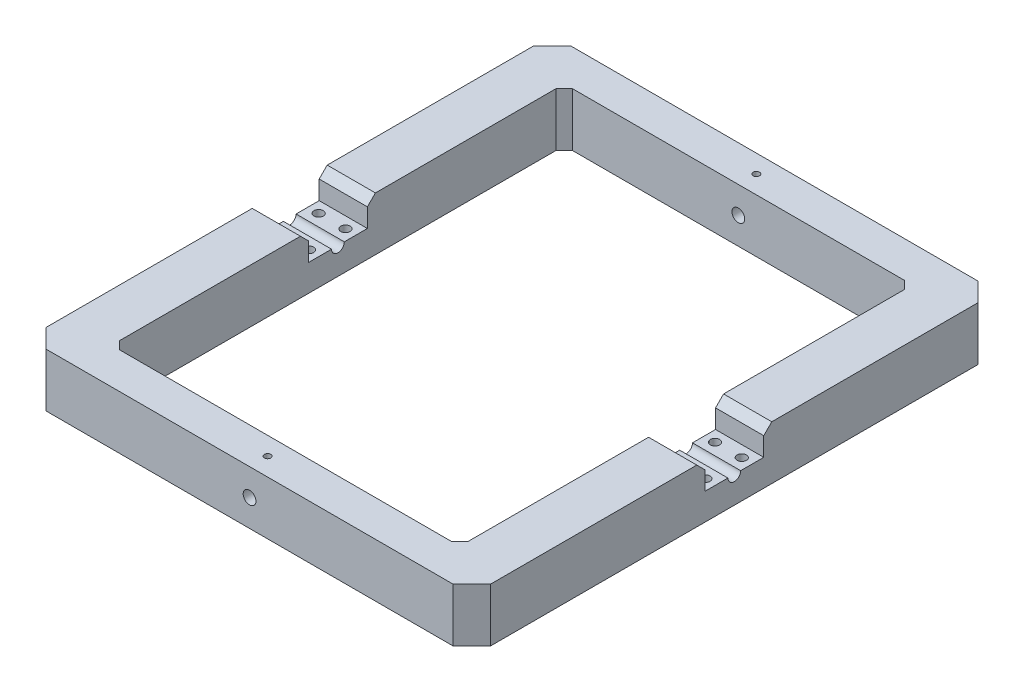
from build123d import *

# Parameters (mm, degrees)
SKETCH1_W               = 166
SKETCH1_H               = 196
SKETCH1_W_2             = 130
SKETCH1_H_2             = 160
BOSS_EXTRUDE1_DEPTH     = 10
CUT_EXTRUDE1_REACH      = 168
SKETCH2_R               = 2.38125
CUT_EXTRUDE2_DEPTH      = 167
SKETCH5_R               = 2.38125
CUT_EXTRUDE4_DEPTH      = 1
CUT_EXTRUDE4_DEPTH_BACK = 197
CUT_EXTRUDE5_REACH      = 12
SKETCH6_R               = 1.75
CUT_EXTRUDE7_REACH      = 22
SKETCH8_W               = 130
SKETCH8_H               = 4.5
CHAMFER9_SIZE           = 7
CHAMFER10_SIZE          = 3
CUT_EXTRUDE8_REACH      = 22
SKETCH9_R               = 1.190625
CHAMFER11_SIZE          = 3


with BuildPart() as part:
    # Sketch1 → Boss-Extrude1 (new body, symmetric)
    with BuildSketch(Plane(origin=(0, 0, 0), x_dir=(1, 0, 0), z_dir=(0, 1, 0))):
        Rectangle(SKETCH1_W, SKETCH1_H)
        Rectangle(SKETCH1_W_2, SKETCH1_H_2, mode=Mode.SUBTRACT)
    extrude(amount=BOSS_EXTRUDE1_DEPTH, both=True)

    # Sketch2 → Cut-Extrude1 (cut, up to next)
    with BuildSketch(Plane(origin=(83, 0, 0), x_dir=(0, 0, -1), z_dir=(1, 0, 0)), mode=Mode.PRIVATE) as cut_extrude1_sk1:
        Circle(SKETCH2_R)
    cut_extrude1_tool1 = extrude(cut_extrude1_sk1.sketch, amount=-CUT_EXTRUDE1_REACH, mode=Mode.PRIVATE) & part.part
    add(cut_extrude1_tool1.solids().sort_by_distance((83, 0, 0))[0], mode=Mode.SUBTRACT)

    # Sketch3 → Cut-Extrude2 (cut, through all)
    with BuildSketch(Plane.ZY.offset(83)):
        with BuildLine():
            ThreePointArc((-2.38125, 0), (0, 2.38125), (2.38125, 0))
            Line((2.38125, 0), (11, 0))
            Line((11, 0), (11, 10))
            Line((11, 10), (-11, 10))
            Line((-11, 10), (-11, 0))
            Line((-11, 0), (-2.38125, 0))
        make_face()
        with BuildLine():
            ThreePointArc((-2.38125, 0), (0, -2.38125), (2.38125, 0))
            Line((2.38125, 0), (-2.38125, 0))
        make_face()
        with BuildLine():
            Line((-2.38125, 0), (2.38125, 0))
            ThreePointArc((2.38125, 0), (0, 2.38125), (-2.38125, 0))
        make_face()
    extrude(amount=-CUT_EXTRUDE2_DEPTH, mode=Mode.SUBTRACT)

    # Sketch5 → Cut-Extrude4 (cut, two sides)
    with BuildSketch(Plane.XY.offset(98)) as cut_extrude4_sk:
        Circle(SKETCH5_R)
    extrude(amount=CUT_EXTRUDE4_DEPTH, mode=Mode.SUBTRACT)
    extrude(cut_extrude4_sk.sketch, amount=-CUT_EXTRUDE4_DEPTH_BACK, mode=Mode.SUBTRACT)

    # Sketch6 → Cut-Extrude5 (cut, up to next)
    with BuildSketch(Plane(origin=(0, 0, 0), x_dir=(1, 0, 0), z_dir=(0, 1, 0)), mode=Mode.PRIVATE) as cut_extrude5_sk1:
        with Locations((-69, 6.8)):
            Circle(SKETCH6_R)
    cut_extrude5_tool1 = extrude(cut_extrude5_sk1.sketch, amount=-CUT_EXTRUDE5_REACH, mode=Mode.PRIVATE) & part.part
    add(cut_extrude5_tool1.solids().sort_by_distance((-69, 0, -6.8))[0], mode=Mode.SUBTRACT)
    # Sketch6 → Cut-Extrude5 (cut, up to next)
    with BuildSketch(Plane(origin=(0, 0, 0), x_dir=(1, 0, 0), z_dir=(0, 1, 0)), mode=Mode.PRIVATE) as cut_extrude5_sk2:
        with Locations((-69, -6.8)):
            Circle(SKETCH6_R)
    cut_extrude5_tool2 = extrude(cut_extrude5_sk2.sketch, amount=-CUT_EXTRUDE5_REACH, mode=Mode.PRIVATE) & part.part
    add(cut_extrude5_tool2.solids().sort_by_distance((-69, 0, 6.8))[0], mode=Mode.SUBTRACT)
    # Sketch6 → Cut-Extrude5 (cut, up to next)
    with BuildSketch(Plane(origin=(0, 0, 0), x_dir=(1, 0, 0), z_dir=(0, 1, 0)), mode=Mode.PRIVATE) as cut_extrude5_sk3:
        with Locations((-79, -6.8)):
            Circle(SKETCH6_R)
    cut_extrude5_tool3 = extrude(cut_extrude5_sk3.sketch, amount=-CUT_EXTRUDE5_REACH, mode=Mode.PRIVATE) & part.part
    add(cut_extrude5_tool3.solids().sort_by_distance((-79, 0, 6.8))[0], mode=Mode.SUBTRACT)
    # Sketch6 → Cut-Extrude5 (cut, up to next)
    with BuildSketch(Plane(origin=(0, 0, 0), x_dir=(1, 0, 0), z_dir=(0, 1, 0)), mode=Mode.PRIVATE) as cut_extrude5_sk4:
        with Locations((-79, 6.8)):
            Circle(SKETCH6_R)
    cut_extrude5_tool4 = extrude(cut_extrude5_sk4.sketch, amount=-CUT_EXTRUDE5_REACH, mode=Mode.PRIVATE) & part.part
    add(cut_extrude5_tool4.solids().sort_by_distance((-79, 0, -6.8))[0], mode=Mode.SUBTRACT)
    # Sketch6 → Cut-Extrude5 (cut, up to next)
    with BuildSketch(Plane(origin=(0, 0, 0), x_dir=(1, 0, 0), z_dir=(0, 1, 0)), mode=Mode.PRIVATE) as cut_extrude5_sk5:
        with Locations((79, 6.8)):
            Circle(SKETCH6_R)
    cut_extrude5_tool5 = extrude(cut_extrude5_sk5.sketch, amount=-CUT_EXTRUDE5_REACH, mode=Mode.PRIVATE) & part.part
    add(cut_extrude5_tool5.solids().sort_by_distance((79, 0, -6.8))[0], mode=Mode.SUBTRACT)
    # Sketch6 → Cut-Extrude5 (cut, up to next)
    with BuildSketch(Plane(origin=(0, 0, 0), x_dir=(1, 0, 0), z_dir=(0, 1, 0)), mode=Mode.PRIVATE) as cut_extrude5_sk6:
        with Locations((79, -6.8)):
            Circle(SKETCH6_R)
    cut_extrude5_tool6 = extrude(cut_extrude5_sk6.sketch, amount=-CUT_EXTRUDE5_REACH, mode=Mode.PRIVATE) & part.part
    add(cut_extrude5_tool6.solids().sort_by_distance((79, 0, 6.8))[0], mode=Mode.SUBTRACT)
    # Sketch6 → Cut-Extrude5 (cut, up to next)
    with BuildSketch(Plane(origin=(0, 0, 0), x_dir=(1, 0, 0), z_dir=(0, 1, 0)), mode=Mode.PRIVATE) as cut_extrude5_sk7:
        with Locations((69, -6.8)):
            Circle(SKETCH6_R)
    cut_extrude5_tool7 = extrude(cut_extrude5_sk7.sketch, amount=-CUT_EXTRUDE5_REACH, mode=Mode.PRIVATE) & part.part
    add(cut_extrude5_tool7.solids().sort_by_distance((69, 0, 6.8))[0], mode=Mode.SUBTRACT)
    # Sketch6 → Cut-Extrude5 (cut, up to next)
    with BuildSketch(Plane(origin=(0, 0, 0), x_dir=(1, 0, 0), z_dir=(0, 1, 0)), mode=Mode.PRIVATE) as cut_extrude5_sk8:
        with Locations((69, 6.8)):
            Circle(SKETCH6_R)
    cut_extrude5_tool8 = extrude(cut_extrude5_sk8.sketch, amount=-CUT_EXTRUDE5_REACH, mode=Mode.PRIVATE) & part.part
    add(cut_extrude5_tool8.solids().sort_by_distance((69, 0, -6.8))[0], mode=Mode.SUBTRACT)

    # Sketch8 → Cut-Extrude7 (cut, up to next)
    with BuildSketch(Plane(origin=(0, 10, 0), x_dir=(1, 0, 0), z_dir=(0, 1, 0)), mode=Mode.PRIVATE) as cut_extrude7_sk1:
        with Locations((0, 82.25)):
            Rectangle(SKETCH8_W, SKETCH8_H)
    cut_extrude7_tool1 = extrude(cut_extrude7_sk1.sketch, amount=-CUT_EXTRUDE7_REACH, mode=Mode.PRIVATE) & part.part
    add(cut_extrude7_tool1.solids().sort_by_distance((0, 10, -82.25))[0], mode=Mode.SUBTRACT)
    # Sketch8 → Cut-Extrude7 (cut, up to next)
    with BuildSketch(Plane(origin=(0, 10, 0), x_dir=(1, 0, 0), z_dir=(0, 1, 0)), mode=Mode.PRIVATE) as cut_extrude7_sk2:
        with Locations((0, -82.25)):
            Rectangle(SKETCH8_W, SKETCH8_H)
    cut_extrude7_tool2 = extrude(cut_extrude7_sk2.sketch, amount=-CUT_EXTRUDE7_REACH, mode=Mode.PRIVATE) & part.part
    add(cut_extrude7_tool2.solids().sort_by_distance((0, 10, 82.25))[0], mode=Mode.SUBTRACT)

    # Chamfer9
    chamfer9_edges = [part.edges().sort_by_distance(p)[0] for p in [
        (83, 0, -98),
        (83, 0, 98),
        (-83, 0, 98),
        (-83, 0, -98),
    ]]
    chamfer(chamfer9_edges, length=CHAMFER9_SIZE)

    # Chamfer10
    chamfer10_edges = [part.edges().sort_by_distance(p)[0] for p in [
        (-65, 0, -84.5),
        (65, 0, -84.5),
        (65, 0, 84.5),
        (-65, 0, 84.5),
    ]]
    chamfer(chamfer10_edges, length=CHAMFER10_SIZE)

    # Sketch9 → Cut-Extrude8 (cut, up to next)
    with BuildSketch(Plane(origin=(0, 10, 0), x_dir=(1, 0, 0), z_dir=(0, 1, 0)), mode=Mode.PRIVATE) as cut_extrude8_sk1:
        with Locations((0, 91.25)):
            Circle(SKETCH9_R)
    cut_extrude8_tool1 = extrude(cut_extrude8_sk1.sketch, amount=-CUT_EXTRUDE8_REACH, mode=Mode.PRIVATE) & part.part
    add(cut_extrude8_tool1.solids().sort_by_distance((0, 10, -91.25))[0], mode=Mode.SUBTRACT)
    # Sketch9 → Cut-Extrude8 (cut, up to next)
    with BuildSketch(Plane(origin=(0, 10, 0), x_dir=(1, 0, 0), z_dir=(0, 1, 0)), mode=Mode.PRIVATE) as cut_extrude8_sk2:
        with Locations((0, -91.25)):
            Circle(SKETCH9_R)
    cut_extrude8_tool2 = extrude(cut_extrude8_sk2.sketch, amount=-CUT_EXTRUDE8_REACH, mode=Mode.PRIVATE) & part.part
    add(cut_extrude8_tool2.solids().sort_by_distance((0, 10, 91.25))[0], mode=Mode.SUBTRACT)

    # Chamfer11
    chamfer11_edges = [part.edges().sort_by_distance(p)[0] for p in [
        (74, 10, -11),
        (74, 10, 11),
        (-74, 10, -11),
        (-74, 10, 11),
    ]]
    chamfer(chamfer11_edges, length=CHAMFER11_SIZE)


solid = part.part
